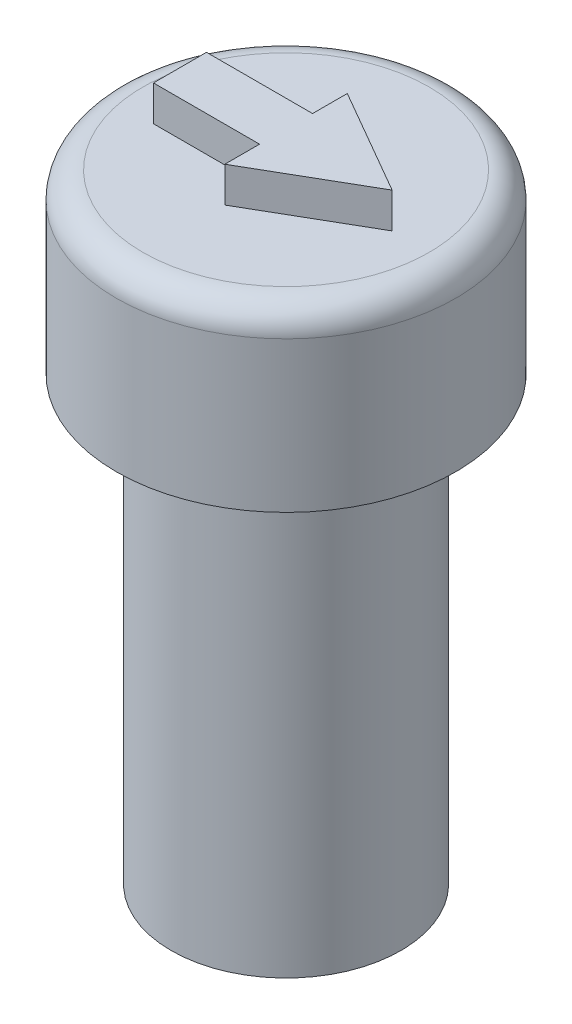
from build123d import *

# Parameters (mm, degrees)
SKETCH1_R           = 3.25
BOSS_EXTRUDE1_DEPTH = 12.5
SKETCH2_R           = 1.75
CUT_EXTRUDE1_DEPTH  = 2.5
SKETCH6_R           = 4.8
BOSS_EXTRUDE2_DEPTH = 5
FILLET1_R           = 0.75
BOSS_EXTRUDE3_DEPTH = 1


with BuildPart() as part:
    # Sketch1 → Boss-Extrude1 (new body)
    with BuildSketch(Plane(origin=(0, 0, 0), x_dir=(1, 0, 0), z_dir=(0, 1, 0))):
        Circle(SKETCH1_R)
    extrude(amount=BOSS_EXTRUDE1_DEPTH)

    # Sketch2 → Cut-Extrude1 (cut)
    with BuildSketch(Plane.XZ):
        Circle(SKETCH2_R)
    extrude(amount=-CUT_EXTRUDE1_DEPTH, mode=Mode.SUBTRACT)

    # Sketch6 → Boss-Extrude2 (add)
    with BuildSketch(Plane(origin=(0, 12.5, 0), x_dir=(1, 0, 0), z_dir=(0, 1, 0))):
        Circle(SKETCH6_R)
    extrude(amount=BOSS_EXTRUDE2_DEPTH)

    # Fillet1
    fillet1_edges = [part.edges().sort_by_distance(p)[0] for p in [
        (-4.8, 17.5, 0),
    ]]
    fillet(fillet1_edges, radius=FILLET1_R)

    # Sketch8 → Boss-Extrude3 (add)
    with BuildSketch(Plane(origin=(0, 17.5, 0), x_dir=(1, 0, 0), z_dir=(0, 1, 0))):
        Polygon((0, 0.75), (-3, 0.75), (-3, -0.75), (0, -0.75), (0, -1.732050808), (3, 0), (0, 1.732050808), align=None)
    extrude(amount=BOSS_EXTRUDE3_DEPTH)


solid = part.part
